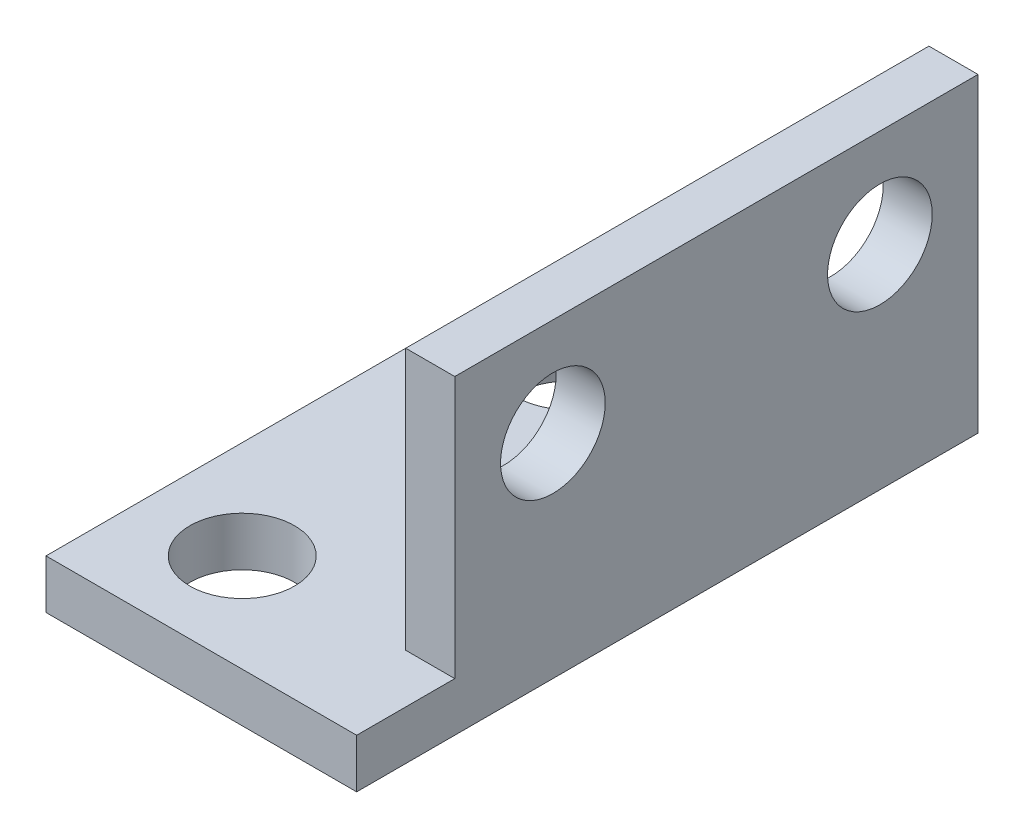
from build123d import *

# Parameters (mm, degrees)
SKETCH1_R           = 1.6
BOSS_EXTRUDE2_DEPTH = 1.5
SKETCH3_W           = 1.5
SKETCH3_H           = 21
BOSS_EXTRUDE3_DEPTH = 8
SKETCH4_R           = 1.6
CUT_EXTRUDE2_DEPTH  = 8
SKETCH6_W           = 5
SKETCH6_H           = 8
CUT_EXTRUDE3_DEPTH  = 8
SKETCH7_W           = 8
SKETCH7_H           = 5
CUT_EXTRUDE4_DEPTH  = 8
SKETCH8_R           = 1.6
SKETCH8_W           = 2
SKETCH8_H           = 9.5
CUT_EXTRUDE5_DEPTH  = 1.5
BOSS_EXTRUDE4_DEPTH = 1.5


with BuildPart() as part:
    # Sketch1 → Boss-Extrude2 (new body)
    with BuildSketch(Plane(origin=(0, 0, 0), x_dir=(1, 0, 0), z_dir=(0, 1, 0))):
        Polygon((-3, 8), (-3, -13), (0, -13), (6.5, -13), (6.5, 0), (6.5, 8), (0, 8), align=None)
        Circle(SKETCH1_R, mode=Mode.SUBTRACT)
        with Locations((0, -10)):
            Circle(SKETCH1_R, mode=Mode.SUBTRACT)
    extrude(amount=BOSS_EXTRUDE2_DEPTH)

    # Sketch3 → Boss-Extrude3 (add)
    with BuildSketch(Plane(origin=(0, 1.5, 0), x_dir=(1, 0, 0), z_dir=(0, 1, 0))):
        with Locations((5.75, -2.5)):
            Rectangle(SKETCH3_W, SKETCH3_H)
    extrude(amount=BOSS_EXTRUDE3_DEPTH)

    # Sketch4 → Cut-Extrude2 (cut)
    with BuildSketch(Plane.ZY.offset(-5)):
        with Locations((-5, 6.5)):
            Circle(SKETCH4_R)
        with Locations((5, 6.5)):
            Circle(SKETCH4_R)
    extrude(amount=-CUT_EXTRUDE2_DEPTH, mode=Mode.SUBTRACT)

    # Sketch6 → Cut-Extrude3 (cut)
    with BuildSketch(Plane.ZY.offset(-5)):
        with Locations((10.5, 5.5)):
            Rectangle(SKETCH6_W, SKETCH6_H)
    extrude(amount=-CUT_EXTRUDE3_DEPTH, mode=Mode.SUBTRACT)

    # Sketch7 → Cut-Extrude4 (cut)
    with BuildSketch(Plane(origin=(0, 1.5, 0), x_dir=(1, 0, 0), z_dir=(0, 1, 0))):
        with Locations((1, 5.5)):
            Rectangle(SKETCH7_W, SKETCH7_H)
    extrude(amount=-CUT_EXTRUDE4_DEPTH, mode=Mode.SUBTRACT)

    # Sketch8 → Cut-Extrude5 (cut)
    with BuildSketch(Plane(origin=(6.5, 0, 0), x_dir=(0, 0, -1), z_dir=(1, 0, 0))):
        with Locations((-7, 6.5)):
            Circle(SKETCH8_R)
        with Locations((3, 6.5)):
            Circle(SKETCH8_R)
        with Locations((7, 4.75)):
            Rectangle(SKETCH8_W, SKETCH8_H)
    extrude(amount=-CUT_EXTRUDE5_DEPTH, mode=Mode.SUBTRACT)

    # Sketch9 → Boss-Extrude4 (add)
    with BuildSketch(Plane(origin=(6.5, 0, 0), x_dir=(0, 0, -1), z_dir=(1, 0, 0))):
        with BuildLine():
            Line((-8, 7.7489996), (-8, 9.5))
            Line((-8, 9.5), (-10, 9.5))
            Line((-10, 9.5), (-10, 1.5))
            Line((-10, 1.5), (-8, 1.5))
            Line((-8, 1.5), (-8, 5.2510004))
            ThreePointArc((-8, 5.2510004), (-8.6, 6.5), (-8, 7.7489996))
        make_face()
        with BuildLine():
            ThreePointArc((-6, 5.2510004), (-3.4, 6.5), (-6, 7.7489996))
            ThreePointArc((-6, 7.7489996), (-5.55777949, 7.192820323), (-5.4, 6.5))
            ThreePointArc((-5.4, 6.5), (-5.55777949, 5.807179677), (-6, 5.2510004))
        make_face()
        with BuildLine():
            ThreePointArc((4, 5.2510004), (4.6, 6.5), (4, 7.7489996))
            ThreePointArc((4, 7.7489996), (5, 8.1), (6, 7.7489996))
            Line((6, 7.7489996), (6, 5.2510004))
            ThreePointArc((6, 5.2510004), (5, 4.9), (4, 5.2510004))
        make_face()
        with BuildLine():
            Line((6, 0), (6, 5.2510004))
            ThreePointArc((6, 5.2510004), (5, 4.9), (4, 5.2510004))
            ThreePointArc((4, 5.2510004), (1.4, 6.5), (4, 7.7489996))
            ThreePointArc((4, 7.7489996), (5, 8.1), (6, 7.7489996))
            Line((6, 7.7489996), (6, 9.5))
            Line((6, 9.5), (-8, 9.5))
            Line((-8, 9.5), (-8, 7.7489996))
            ThreePointArc((-8, 7.7489996), (-7, 8.1), (-6, 7.7489996))
            ThreePointArc((-6, 7.7489996), (-3.4, 6.5), (-6, 5.2510004))
            ThreePointArc((-6, 5.2510004), (-7, 4.9), (-8, 5.2510004))
            Line((-8, 5.2510004), (-8, 1.5))
            Line((-8, 1.5), (-13, 1.5))
            Line((-13, 1.5), (-13, 0))
            Line((-13, 0), (6, 0))
        make_face()
    extrude(amount=-BOSS_EXTRUDE4_DEPTH)


solid = part.part
